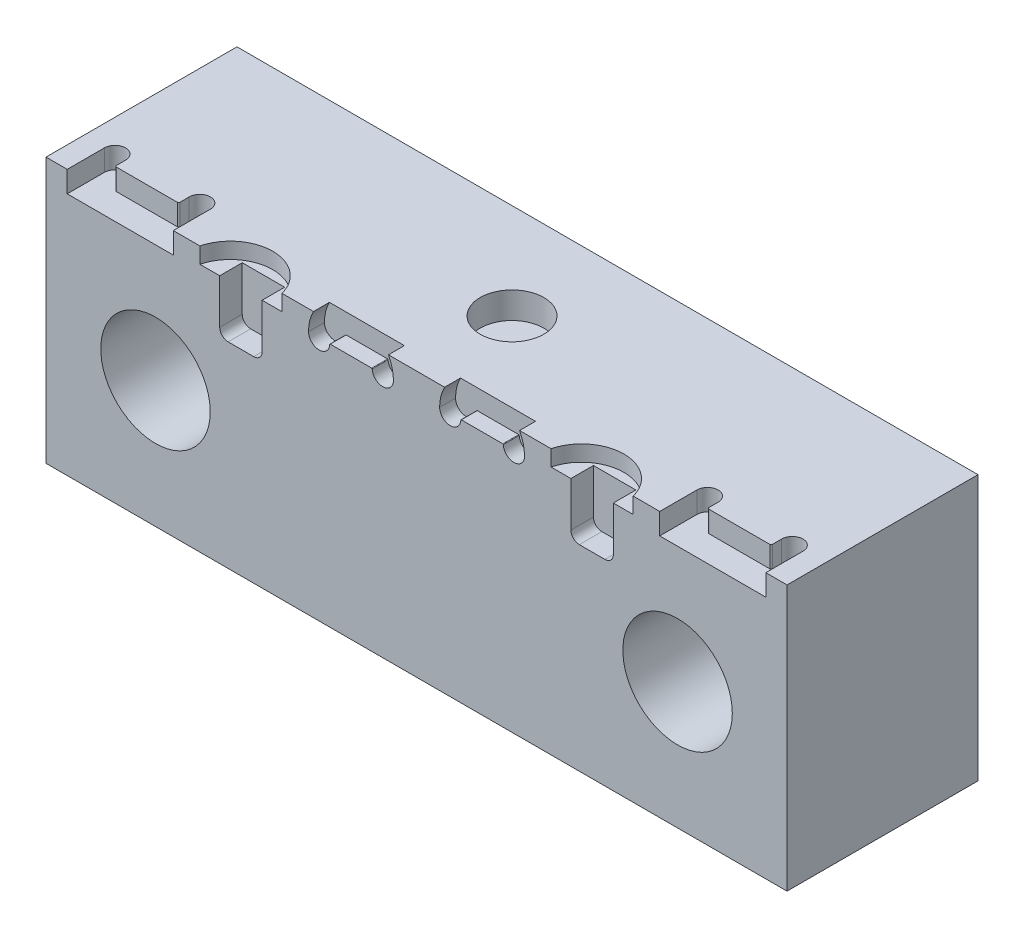
from build123d import *

# Parameters (mm, degrees)
SKETCH1_W                                        = 36
SKETCH1_H                                        = 50
BOSS_EXTRUDE1_DEPTH                              = 69.85
CBORE_FOR_1_2_SOCKET_HEAD_CAP_SCREW1_D           = 13.89126
CBORE_FOR_1_2_SOCKET_HEAD_CAP_SCREW1_CBORE_D     = 20.6375
CBORE_FOR_1_2_SOCKET_HEAD_CAP_SCREW1_CBORE_DEPTH = 27.94
CUT_EXTRUDE1_DEPTH                               = 4
CUT_EXTRUDE2_DEPTH                               = 3
CUT_EXTRUDE4_DEPTH                               = 4.25
CUT_EXTRUDE5_DEPTH                               = 3
SKETCH10_R                                       = 6
CUT_EXTRUDE6_DEPTH                               = 5
FILLET1_R                                        = 0.1
FILLET2_R                                        = 0.254


with BuildPart() as part:
    # Sketch1 → Boss-Extrude1 (new body, symmetric)
    with BuildSketch(Plane(origin=(0, 0, 0), x_dir=(0, 0, -1), z_dir=(1, 0, 0))):
        Rectangle(SKETCH1_W, SKETCH1_H)
    extrude(amount=BOSS_EXTRUDE1_DEPTH, both=True)

    # CBORE for 1/2 Socket Head Cap Screw1 (through all)
    with Locations(Plane.XY.offset(18)):
        with Locations((-49.2125, -1.124), (49.2125, -1.124)):
            CounterBoreHole(CBORE_FOR_1_2_SOCKET_HEAD_CAP_SCREW1_D / 2, CBORE_FOR_1_2_SOCKET_HEAD_CAP_SCREW1_CBORE_D / 2, CBORE_FOR_1_2_SOCKET_HEAD_CAP_SCREW1_CBORE_DEPTH)

    # Sketch5 → Cut-Extrude1 (cut)
    with BuildSketch(Plane(origin=(0, 25, 0), x_dir=(1, 0, 0), z_dir=(0, 1, 0))):
        with BuildLine():
            Line((-65.85, -18), (-45.85, -18))
            Line((-45.85, -18), (-45.85, -11))
            ThreePointArc((-45.85, -11), (-47.85, -9), (-49.85, -11))
            Line((-49.85, -11), (-49.85, -13))
            Line((-49.85, -13), (-61.85, -13))
            Line((-61.85, -13), (-61.85, -11))
            ThreePointArc((-61.85, -11), (-63.85, -9), (-65.85, -11))
            Line((-65.85, -11), (-65.85, -18))
        make_face()
        with BuildLine():
            Line((45.85, -18), (65.85, -18))
            Line((65.85, -18), (65.85, -11))
            ThreePointArc((65.85, -11), (63.85, -9), (61.85, -11))
            Line((61.85, -11), (61.85, -13))
            Line((61.85, -13), (49.85, -13))
            Line((49.85, -13), (49.85, -11))
            ThreePointArc((49.85, -11), (47.85, -9), (45.85, -11))
            Line((45.85, -11), (45.85, -18))
        make_face()
    extrude(amount=-CUT_EXTRUDE1_DEPTH, mode=Mode.SUBTRACT)

    # Sketch6 → Cut-Extrude2 (cut)
    with BuildSketch(Plane(origin=(0, 25, 0), x_dir=(1, 0, 0), z_dir=(0, 1, 0))):
        with BuildLine():
            Line((-40.85, -18), (-25.358066615, -18))
            ThreePointArc((-25.358066615, -18), (-33.104033308, -12), (-40.85, -18))
        make_face()
        with BuildLine():
            Line((25.358066615, -18), (40.85, -18))
            ThreePointArc((40.85, -18), (33.104033308, -12), (25.358066615, -18))
        make_face()
    extrude(amount=-CUT_EXTRUDE2_DEPTH, mode=Mode.SUBTRACT)

    # Sketch8 → Cut-Extrude4 (cut)
    with BuildSketch(Plane.XY.offset(18)):
        with BuildLine():
            Line((-37.104033308, 22), (-29.104033308, 22))
            Line((-29.104033308, 22), (-29.104033308, 13.5875))
            ThreePointArc((-29.104033308, 13.5875), (-29.569001292, 12.464967985), (-30.691533308, 12))
            Line((-30.691533308, 12), (-35.516533308, 12))
            ThreePointArc((-35.516533308, 12), (-36.639065323, 12.464967985), (-37.104033308, 13.5875))
            Line((-37.104033308, 13.5875), (-37.104033308, 22))
        make_face()
        with BuildLine():
            Line((29.104033308, 22), (37.104033308, 22))
            Line((37.104033308, 22), (37.104033308, 13.5875))
            ThreePointArc((37.104033308, 13.5875), (36.639065323, 12.464967985), (35.516533308, 12))
            Line((35.516533308, 12), (30.691533308, 12))
            ThreePointArc((30.691533308, 12), (29.569001292, 12.464967985), (29.104033308, 13.5875))
            Line((29.104033308, 13.5875), (29.104033308, 22))
        make_face()
    extrude(amount=-CUT_EXTRUDE4_DEPTH, mode=Mode.SUBTRACT)

    # Sketch9 → Cut-Extrude5 (cut)
    with BuildSketch(Plane.XY.offset(18)):
        with BuildLine():
            Line((-16.358066615, 21.25), (-8.358066615, 21.25))
            ThreePointArc((-8.358066615, 21.25), (-6.358066615, 19.25), (-4.358066615, 21.25))
            ThreePointArc((-4.358066615, 21.25), (-4.59491081, 23.18220391), (-5.291419603, 25))
            Line((-5.291419603, 25), (-19.424713628, 25))
            ThreePointArc((-19.424713628, 25), (-20.12122242, 23.18220391), (-20.358066615, 21.25))
            ThreePointArc((-20.358066615, 21.25), (-18.358066615, 19.25), (-16.358066615, 21.25))
        make_face()
        with BuildLine():
            Line((5.291419603, 25), (19.424713628, 25))
            ThreePointArc((19.424713628, 25), (20.12122242, 23.18220391), (20.358066615, 21.25))
            ThreePointArc((20.358066615, 21.25), (18.358066615, 19.25), (16.358066615, 21.25))
            Line((16.358066615, 21.25), (8.358066615, 21.25))
            ThreePointArc((8.358066615, 21.25), (6.358066615, 19.25), (4.358066615, 21.25))
            ThreePointArc((4.358066615, 21.25), (4.59491081, 23.18220391), (5.291419603, 25))
        make_face()
    extrude(amount=-CUT_EXTRUDE5_DEPTH, mode=Mode.SUBTRACT)

    # Sketch10 → Cut-Extrude6 (cut)
    with BuildSketch(Plane(origin=(0, 25, 0), x_dir=(1, 0, 0), z_dir=(0, 1, 0))):
        Circle(SKETCH10_R)
    extrude(amount=-CUT_EXTRUDE6_DEPTH, mode=Mode.SUBTRACT)

    # Fillet1
    fillet1_edges = [part.edges().sort_by_distance(p)[0] for p in [
        (-16.358066615, 21.25, 16.5),
        (-8.358066615, 21.25, 16.5),
        (16.358066615, 21.25, 16.5),
        (8.358066615, 21.25, 16.5),
    ]]
    fillet(fillet1_edges, radius=FILLET1_R)

    # Fillet2
    fillet2_edges = [part.edges().sort_by_distance(p)[0] for p in [
        (-61.85, 23, 13),
        (-49.85, 23, 13),
        (49.85, 23, 13),
        (61.85, 23, 13),
    ]]
    fillet(fillet2_edges, radius=FILLET2_R)


solid = part.part
